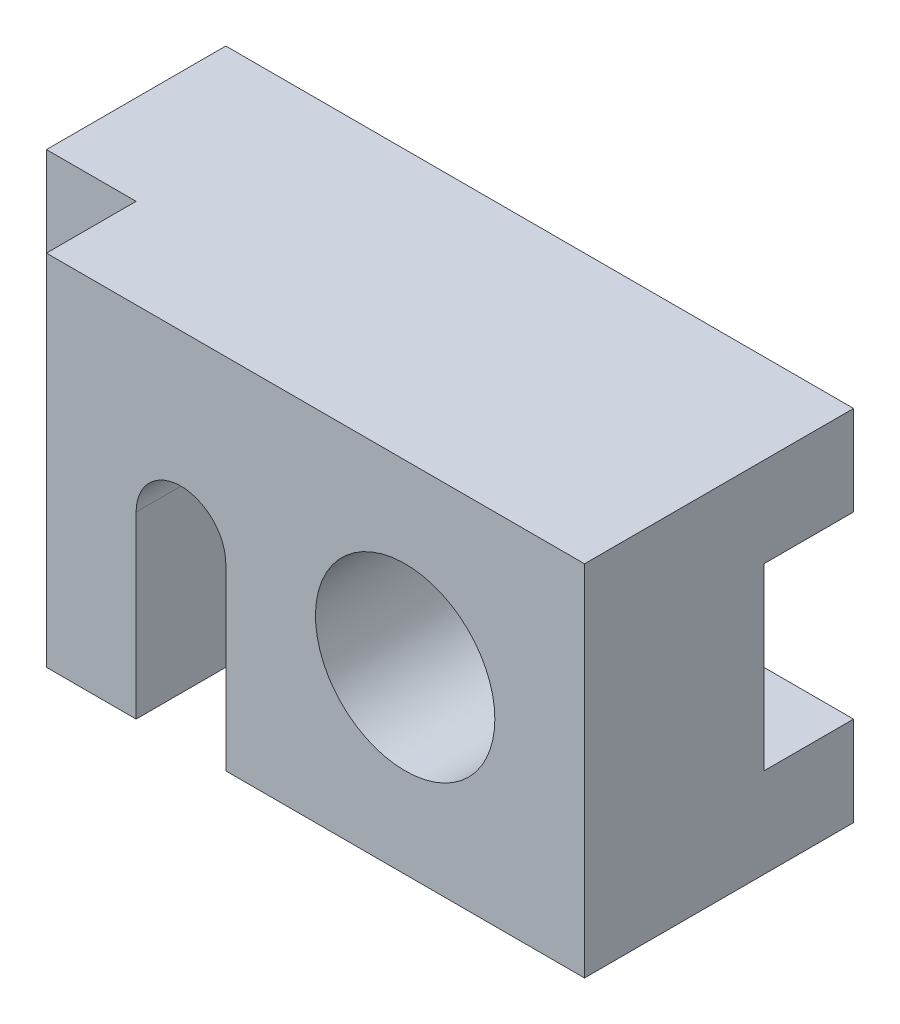
from build123d import *

# Parameters (mm, degrees)
SKETCH1_W           = 84
SKETCH1_H           = 48
SKETCH1_R           = 12
BOSS_EXTRUDE1_DEPTH = 36
SKETCH2_W           = 12
SKETCH2_H           = 12
CUT_EXTRUDE1_DEPTH  = 49
SKETCH3_W           = 12
SKETCH3_H           = 24
CUT_EXTRUDE2_DEPTH  = 85
SKETCH5_W           = 12
SKETCH5_H           = 12
CUT_EXTRUDE4_DEPTH  = 24


with BuildPart() as part:
    # Sketch1 → Boss-Extrude1 (new body)
    with BuildSketch(Plane.XY):
        with Locations((42, 24)):
            Rectangle(SKETCH1_W, SKETCH1_H)
        with BuildLine():
            Line((36, 24), (36, 12))
            Line((36, 12), (24, 12))
            Line((24, 12), (24, 24))
            ThreePointArc((24, 24), (30, 30.000000202), (36, 24))
        make_face(mode=Mode.SUBTRACT)
        with Locations((60, 24)):
            Circle(SKETCH1_R, mode=Mode.SUBTRACT)
    extrude(amount=BOSS_EXTRUDE1_DEPTH)

    # Sketch2 → Cut-Extrude1 (cut, through all)
    with BuildSketch(Plane(origin=(0, 48, 0), x_dir=(1, 0, 0), z_dir=(0, 1, 0))):
        with Locations((6, -30)):
            Rectangle(SKETCH2_W, SKETCH2_H)
    extrude(amount=-CUT_EXTRUDE1_DEPTH, mode=Mode.SUBTRACT)

    # Sketch3 → Cut-Extrude2 (cut, through all)
    with BuildSketch(Plane.ZY):
        with Locations((6, 24)):
            Rectangle(SKETCH3_W, SKETCH3_H)
    extrude(amount=-CUT_EXTRUDE2_DEPTH, mode=Mode.SUBTRACT)

    # Sketch5 → Cut-Extrude4 (cut)
    with BuildSketch(Plane.XY.offset(36)):
        with Locations((30, 6)):
            Rectangle(SKETCH5_W, SKETCH5_H)
    extrude(amount=-CUT_EXTRUDE4_DEPTH, mode=Mode.SUBTRACT)


solid = part.part
